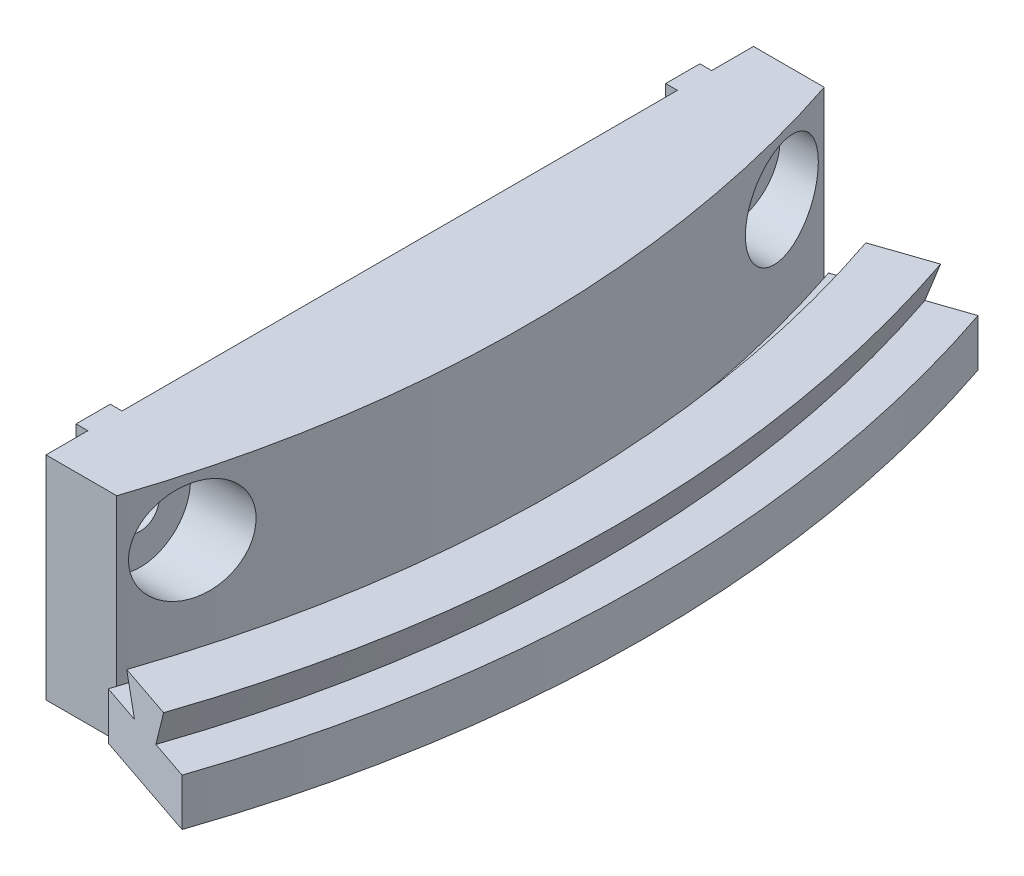
from build123d import *

# Parameters (mm, degrees)
MAIN_ANGLE             = 37.5
SUPPORT_DEPTH          = 18
SKETCH6_W              = 1
SKETCH6_H              = 2.9
MAKERBEAMSUPPORT_DEPTH = 18
SKETCH7_R              = 1.6
HOLESMAKERBEAM_DEPTH   = 22.861218113
SKETCH8_R              = 4.25
CUT_EXTRUDE1_DEPTH     = 7


with BuildPart() as part:
    # Sketch1 → Main (revolve, symmetric)
    with BuildSketch(Plane.XY) as main_sk:
        Polygon((105, 0), (105, 4), (101.45, 4), (102.5, 7), (97.5, 7), (98.55, 4), (95, 4), (95, 0), align=None)
    revolve(axis=Axis((0, -0.284703924, 0), (0, 1, 0)), revolution_arc=MAIN_ANGLE / 2)
    revolve(main_sk.sketch, axis=Axis((0, -0.284703924, 0), (0, -1, 0)), revolution_arc=MAIN_ANGLE / 2)

    # Sketch2 → Support (add)
    with BuildSketch(Plane(origin=(0, 0, 0), x_dir=(-1, 0, 0), z_dir=(0, -1, 0))):
        with BuildLine():
            Line((-90.138781887, -30), (-84.138781887, -30))
            Line((-84.138781887, -30), (-84.138781887, 30))
            Line((-84.138781887, 30), (-90.138781887, 30))
            ThreePointArc((-90.138781887, 30), (-95, 0), (-90.138781887, -30))
        make_face()
    extrude(amount=-SUPPORT_DEPTH)

    # Sketch6 → MakerBeamSupport (add)
    with BuildSketch(Plane(origin=(0, 0, 0), x_dir=(1, 0, 0), z_dir=(0, 1, 0))):
        with Locations((83.638781887, -25)):
            Rectangle(SKETCH6_W, SKETCH6_H)
        with Locations((83.638781887, 25)):
            Rectangle(SKETCH6_W, SKETCH6_H)
    extrude(amount=MAKERBEAMSUPPORT_DEPTH)

    # Sketch7 → HolesMakerBeam (cut, through all)
    with BuildSketch(Plane(origin=(83.138781887, 0, 0), x_dir=(0, 0, -1), z_dir=(1, 0, 0))):
        with Locations((-25, 13)):
            Circle(SKETCH7_R)
        with Locations((25, 13)):
            Circle(SKETCH7_R)
    extrude(amount=HOLESMAKERBEAM_DEPTH, mode=Mode.SUBTRACT)

    # Sketch8 → Cut-Extrude1 (cut)
    with BuildSketch(Plane.ZY.offset(-87.138781887)):
        with Locations((25, 13)):
            Circle(SKETCH8_R)
        with Locations((-25, 13)):
            Circle(SKETCH8_R)
    extrude(amount=-CUT_EXTRUDE1_DEPTH, mode=Mode.SUBTRACT)


solid = part.part
